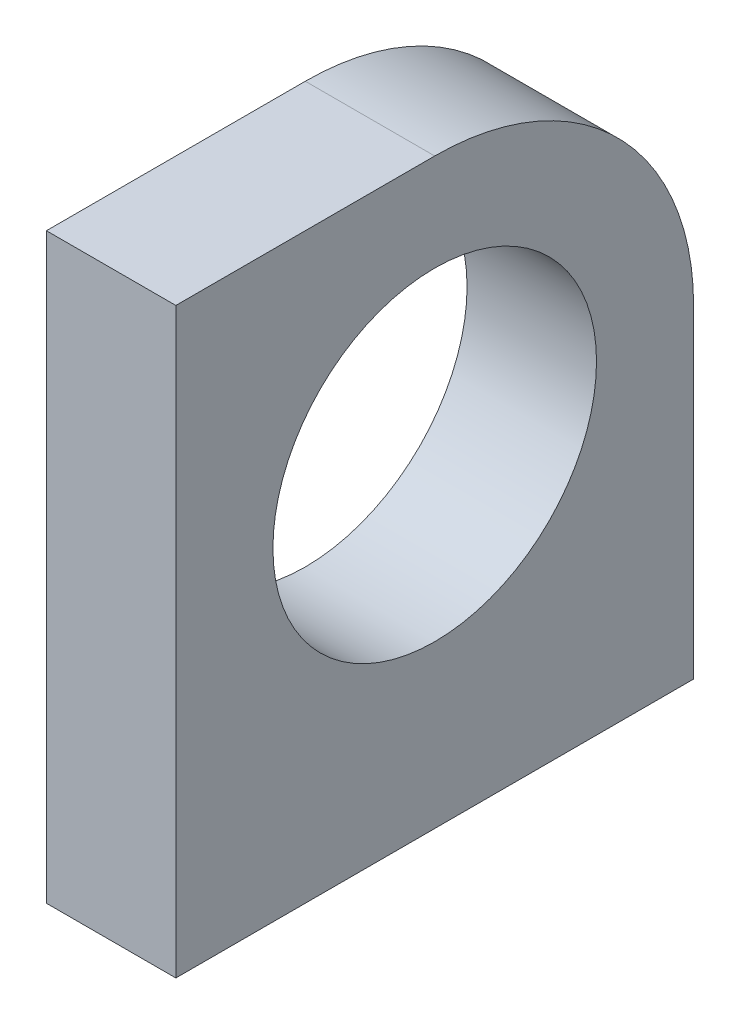
from build123d import *

# Parameters (mm, degrees)
SKETCH1_W           = 50.8
SKETCH1_H           = 57.15
BOSS_EXTRUDE1_DEPTH = 6.35
CUT_EXTRUDE1_REACH  = 14.7
SKETCH2_R           = 15.875
FILLET1_R           = 25.4


with BuildPart() as part:
    # Sketch1 → Boss-Extrude1 (new body, symmetric)
    with BuildSketch(Plane(origin=(0, 0, 0), x_dir=(0, 0, -1), z_dir=(1, 0, 0))):
        Rectangle(SKETCH1_W, SKETCH1_H)
    extrude(amount=BOSS_EXTRUDE1_DEPTH, both=True)

    # Sketch2 → Cut-Extrude1 (cut, up to next)
    with BuildSketch(Plane(origin=(6.35, 0, 0), x_dir=(0, 0, -1), z_dir=(1, 0, 0)), mode=Mode.PRIVATE) as cut_extrude1_sk1:
        with Locations((0, 3.175)):
            Circle(SKETCH2_R)
    cut_extrude1_tool1 = extrude(cut_extrude1_sk1.sketch, amount=-CUT_EXTRUDE1_REACH, mode=Mode.PRIVATE) & part.part
    add(cut_extrude1_tool1.solids().sort_by_distance((6.35, 3.175, 0))[0], mode=Mode.SUBTRACT)

    # Fillet1
    fillet1_edges = [part.edges().sort_by_distance(p)[0] for p in [
        (0, 28.575, -25.4),
    ]]
    fillet(fillet1_edges, radius=FILLET1_R)


solid = part.part
